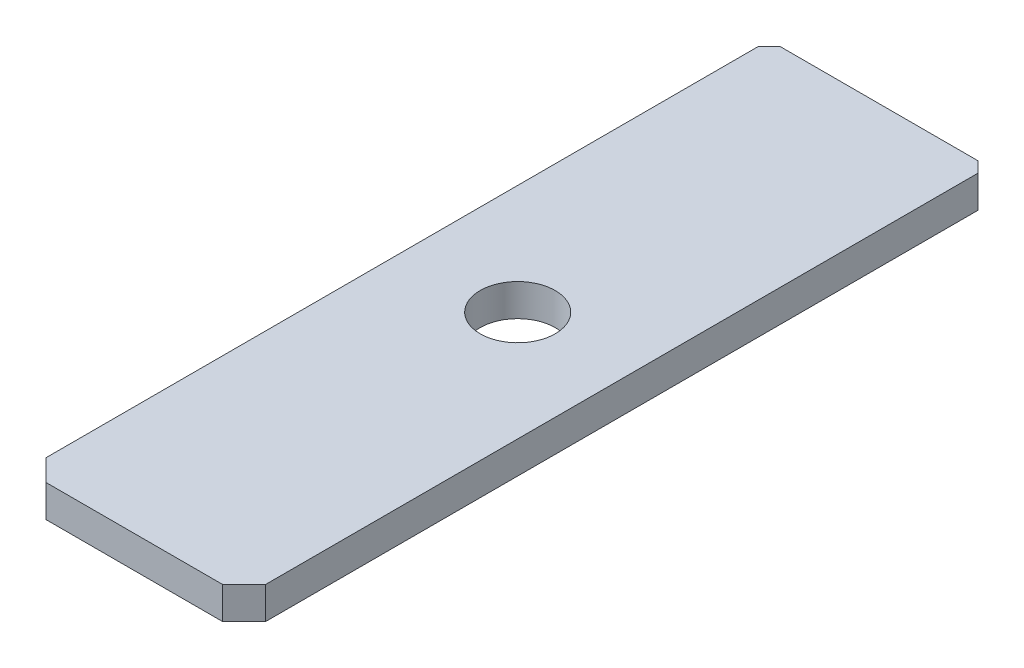
from build123d import *

# Parameters (mm, degrees)
SKETCH1_W           = 10.24
SKETCH1_H           = 34.73
BOSS_EXTRUDE1_DEPTH = 1.5
CHAMFER1_SIZE       = 0.5
CHAMFER2_SIZE       = 1
SKETCH2_R           = 1.75
CUT_EXTRUDE1_DEPTH  = 2.5


with BuildPart() as part:
    # Sketch1 → Boss-Extrude1 (new body)
    with BuildSketch(Plane(origin=(0, 0, 0), x_dir=(1, 0, 0), z_dir=(0, 1, 0))):
        Rectangle(SKETCH1_W, SKETCH1_H)
    extrude(amount=BOSS_EXTRUDE1_DEPTH)

    # Chamfer1
    chamfer1_edges = [part.edges().sort_by_distance(p)[0] for p in [
        (-5.12, 0.75, -17.365),
        (5.12, 0.75, -17.365),
    ]]
    chamfer(chamfer1_edges, length=CHAMFER1_SIZE)

    # Chamfer2
    chamfer2_edges = [part.edges().sort_by_distance(p)[0] for p in [
        (5.12, 0.75, 17.365),
        (-5.12, 0.75, 17.365),
    ]]
    chamfer(chamfer2_edges, length=CHAMFER2_SIZE)

    # Sketch2 → Cut-Extrude1 (cut, through all)
    with BuildSketch(Plane(origin=(0, 1.5, 0), x_dir=(1, 0, 0), z_dir=(0, 1, 0))):
        with Locations((0, 0.515)):
            Circle(SKETCH2_R)
    extrude(amount=-CUT_EXTRUDE1_DEPTH, mode=Mode.SUBTRACT)


solid = part.part
